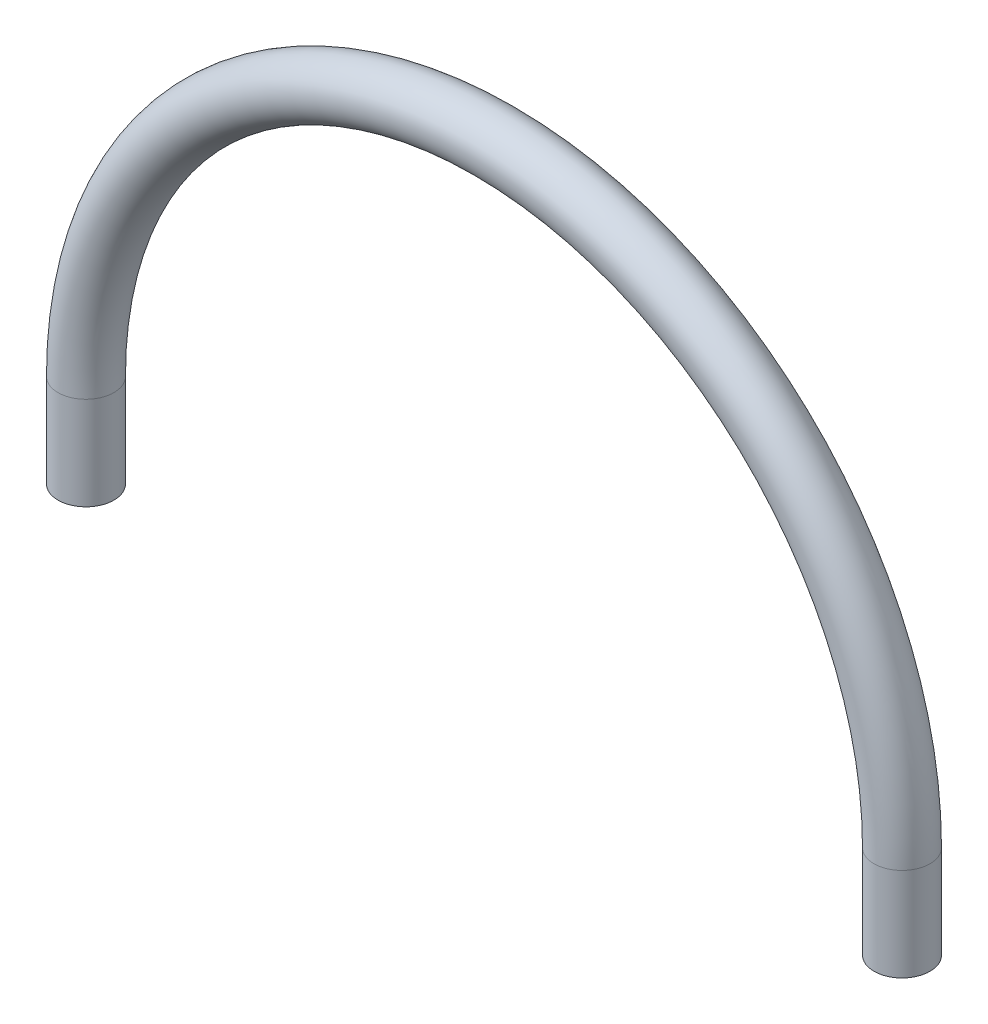
from build123d import *

# Parameters (mm, degrees)
SWEEP1_PROFILE_R = 3.81


with BuildPart() as part:
    # Sweep1: sweep along a path in Sketch2
    with BuildLine(Plane.XY) as sweep1_path:
        Line((-55.626, -12.7), (-55.626, 0))
        ThreePointArc((-55.626, 0), (0, 55.626), (55.626, 0))
        Line((55.626, 0), (55.626, -12.7))
    # Sweep1 profile (on start of the path) → Sweep1 (sweep)
    with BuildSketch(Plane(origin=(-55.626, -12.7, 0), x_dir=(1, 0, 0), z_dir=(0, 1, 0))):
        Circle(SWEEP1_PROFILE_R)
    sweep(path=sweep1_path.line)


solid = part.part
